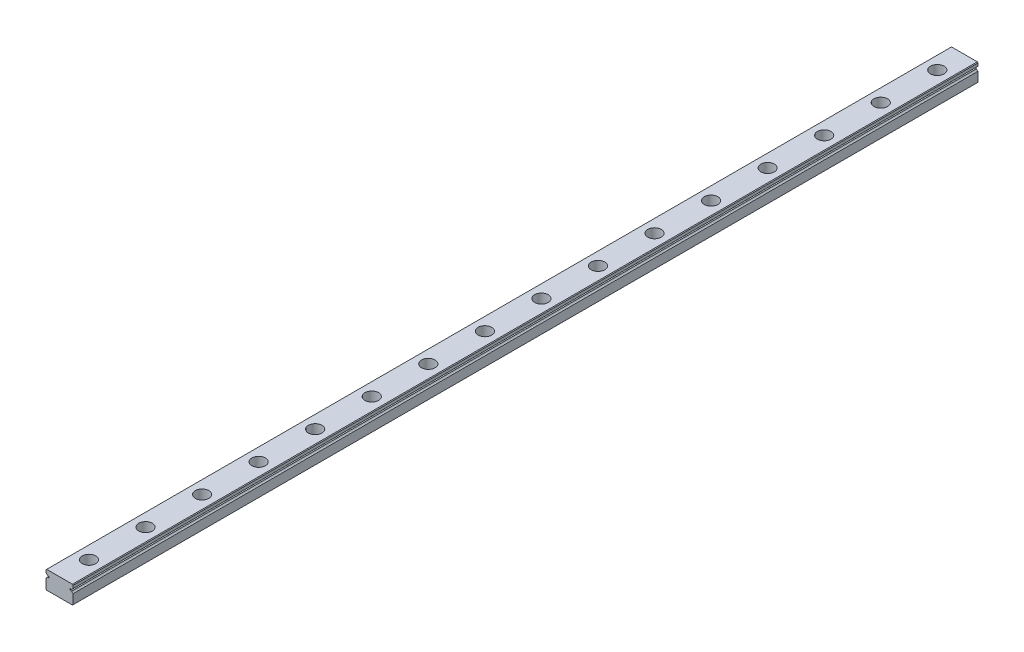
from build123d import *

# Parameters (mm, degrees)
EXTRUDE_1_DEPTH        = 400
SKETCH_2_R             = 3
SKETCH_2_R_2           = 1.75
CUT_EXTRUDE_1_DEPTH    = 4.5
SKETCH_2_2_R           = 1.75
CUT_EXTRUDE_2_DEPTH    = 401.124980475
PATTERN_LINEAR_1_COUNT = 16
PATTERN_LINEAR_1_PITCH = 25


with BuildPart() as part:
    # Эскиз1 → Бобышка-Вытянуть1 (new body)
    with BuildSketch(Plane.XY):
        with BuildLine():
            Line((-6, 3.7), (-5.7, 4))
            Line((-5.7, 4), (5.7, 4))
            Line((5.7, 4), (6, 3.7))
            Line((6, 3.7), (6, 2.451013544))
            ThreePointArc((6, 2.451013544), (5.597935912, 2.202976267), (5.354599002, 1.798050138))
            Line((5.354599002, 1.798050138), (4.643514056, 1.798050138))
            Line((4.643514056, 1.798050138), (4.643514056, 1.201949862))
            Line((4.643514056, 1.201949862), (5.354599002, 1.201949862))
            ThreePointArc((5.354599002, 1.201949862), (5.597935912, 0.797023733), (6, 0.548986456))
            Line((6, 0.548986456), (6, -3.7))
            Line((6, -3.7), (5.7, -4))
            Line((5.7, -4), (-5.7, -4))
            Line((-5.7, -4), (-6, -3.7))
            Line((-6, -3.7), (-6, 0.548986456))
            ThreePointArc((-6, 0.548986456), (-5.597935912, 0.797023733), (-5.354599002, 1.201949862))
            Line((-5.354599002, 1.201949862), (-4.643514056, 1.201949862))
            Line((-4.643514056, 1.201949862), (-4.643514056, 1.798050138))
            Line((-4.643514056, 1.798050138), (-5.354599002, 1.798050138))
            ThreePointArc((-5.354599002, 1.798050138), (-5.597935912, 2.202976267), (-6, 2.451013544))
            Line((-6, 2.451013544), (-6, 3.7))
        make_face()
    extrude(amount=EXTRUDE_1_DEPTH)

    # Эскиз2 → Вырез-Вытянуть1 (cut)
    with BuildSketch(Plane(origin=(0, 4, 0), x_dir=(1, 0, 0), z_dir=(0, 1, 0))):
        with Locations((0, -12)):
            Circle(SKETCH_2_R)
        with Locations((0, -12)):
            Circle(SKETCH_2_R_2, mode=Mode.SUBTRACT)
    cut_extrude_1 = extrude(amount=-CUT_EXTRUDE_1_DEPTH, mode=Mode.SUBTRACT)

    # Эскиз2<2> → Вырез-Вытянуть2 (cut, through all)
    with BuildSketch(Plane(origin=(0, 4, 0), x_dir=(1, 0, 0), z_dir=(0, 1, 0))):
        with Locations((0, -12)):
            Circle(SKETCH_2_2_R)
    cut_extrude_2 = extrude(amount=-CUT_EXTRUDE_2_DEPTH, mode=Mode.SUBTRACT)

    # Линейный массив1: Вырез-Вытянуть1, Вырез-Вытянуть2 ×16
    with Locations(*[(0, 0, i * PATTERN_LINEAR_1_PITCH) for i in range(1, PATTERN_LINEAR_1_COUNT)]):
        add(cut_extrude_1, mode=Mode.SUBTRACT)
        add(cut_extrude_2, mode=Mode.SUBTRACT)


solid = part.part
